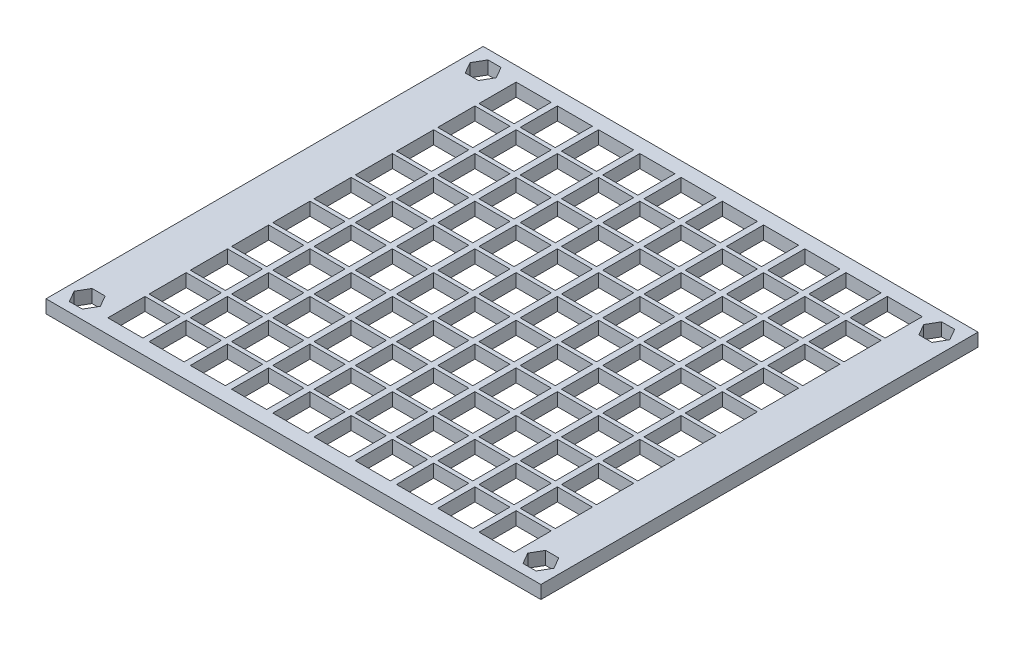
from build123d import *

# Parameters (mm, degrees)
SKETCH1_W           = 120
SKETCH1_H           = 106
SKETCH1_W_2         = 8.5
SKETCH1_H_2         = 9
BOSS_EXTRUDE1_DEPTH = 3.175


with BuildPart() as part:
    # Sketch1 → Boss-Extrude1 (new body)
    with BuildSketch(Plane(origin=(0, 0, 0), x_dir=(1, 0, 0), z_dir=(0, 1, 0))):
        with Locations((60, 53)):
            Rectangle(SKETCH1_W, SKETCH1_H)
        Polygon((6.58771324, 98.25), (8.175426481, 101), (6.58771324, 103.75), (3.41228676, 103.75), (1.824573519, 101), (3.41228676, 98.25), align=None, mode=Mode.SUBTRACT)
        with Locations((25.75, 8)):
            Rectangle(SKETCH1_W_2, SKETCH1_H_2, mode=Mode.SUBTRACT)
        with Locations((15.75, 8)):
            Rectangle(SKETCH1_W_2, SKETCH1_H_2, mode=Mode.SUBTRACT)
        with Locations((35.75, 8)):
            Rectangle(SKETCH1_W_2, SKETCH1_H_2, mode=Mode.SUBTRACT)
        with Locations((45.75, 8)):
            Rectangle(SKETCH1_W_2, SKETCH1_H_2, mode=Mode.SUBTRACT)
        with Locations((55.75, 8)):
            Rectangle(SKETCH1_W_2, SKETCH1_H_2, mode=Mode.SUBTRACT)
        with Locations((65.75, 8)):
            Rectangle(SKETCH1_W_2, SKETCH1_H_2, mode=Mode.SUBTRACT)
        with Locations((75.75, 8)):
            Rectangle(SKETCH1_W_2, SKETCH1_H_2, mode=Mode.SUBTRACT)
        with Locations((85.75, 8)):
            Rectangle(SKETCH1_W_2, SKETCH1_H_2, mode=Mode.SUBTRACT)
        with Locations((95.75, 8)):
            Rectangle(SKETCH1_W_2, SKETCH1_H_2, mode=Mode.SUBTRACT)
        with Locations((105.75, 8)):
            Rectangle(SKETCH1_W_2, SKETCH1_H_2, mode=Mode.SUBTRACT)
        with Locations((25.75, 18)):
            Rectangle(SKETCH1_W_2, SKETCH1_H_2, mode=Mode.SUBTRACT)
        with Locations((35.75, 18)):
            Rectangle(SKETCH1_W_2, SKETCH1_H_2, mode=Mode.SUBTRACT)
        with Locations((45.75, 18)):
            Rectangle(SKETCH1_W_2, SKETCH1_H_2, mode=Mode.SUBTRACT)
        with Locations((55.75, 18)):
            Rectangle(SKETCH1_W_2, SKETCH1_H_2, mode=Mode.SUBTRACT)
        with Locations((65.75, 18)):
            Rectangle(SKETCH1_W_2, SKETCH1_H_2, mode=Mode.SUBTRACT)
        with Locations((75.75, 18)):
            Rectangle(SKETCH1_W_2, SKETCH1_H_2, mode=Mode.SUBTRACT)
        with Locations((85.75, 18)):
            Rectangle(SKETCH1_W_2, SKETCH1_H_2, mode=Mode.SUBTRACT)
        with Locations((95.75, 18)):
            Rectangle(SKETCH1_W_2, SKETCH1_H_2, mode=Mode.SUBTRACT)
        with Locations((105.75, 18)):
            Rectangle(SKETCH1_W_2, SKETCH1_H_2, mode=Mode.SUBTRACT)
        with Locations((25.75, 28)):
            Rectangle(SKETCH1_W_2, SKETCH1_H_2, mode=Mode.SUBTRACT)
        with Locations((35.75, 28)):
            Rectangle(SKETCH1_W_2, SKETCH1_H_2, mode=Mode.SUBTRACT)
        with Locations((45.75, 28)):
            Rectangle(SKETCH1_W_2, SKETCH1_H_2, mode=Mode.SUBTRACT)
        with Locations((55.75, 28)):
            Rectangle(SKETCH1_W_2, SKETCH1_H_2, mode=Mode.SUBTRACT)
        with Locations((65.75, 28)):
            Rectangle(SKETCH1_W_2, SKETCH1_H_2, mode=Mode.SUBTRACT)
        with Locations((75.75, 28)):
            Rectangle(SKETCH1_W_2, SKETCH1_H_2, mode=Mode.SUBTRACT)
        with Locations((85.75, 28)):
            Rectangle(SKETCH1_W_2, SKETCH1_H_2, mode=Mode.SUBTRACT)
        with Locations((95.75, 28)):
            Rectangle(SKETCH1_W_2, SKETCH1_H_2, mode=Mode.SUBTRACT)
        with Locations((105.75, 28)):
            Rectangle(SKETCH1_W_2, SKETCH1_H_2, mode=Mode.SUBTRACT)
        with Locations((25.75, 38)):
            Rectangle(SKETCH1_W_2, SKETCH1_H_2, mode=Mode.SUBTRACT)
        with Locations((35.75, 38)):
            Rectangle(SKETCH1_W_2, SKETCH1_H_2, mode=Mode.SUBTRACT)
        with Locations((45.75, 38)):
            Rectangle(SKETCH1_W_2, SKETCH1_H_2, mode=Mode.SUBTRACT)
        with Locations((55.75, 38)):
            Rectangle(SKETCH1_W_2, SKETCH1_H_2, mode=Mode.SUBTRACT)
        with Locations((65.75, 38)):
            Rectangle(SKETCH1_W_2, SKETCH1_H_2, mode=Mode.SUBTRACT)
        with Locations((75.75, 38)):
            Rectangle(SKETCH1_W_2, SKETCH1_H_2, mode=Mode.SUBTRACT)
        with Locations((85.75, 38)):
            Rectangle(SKETCH1_W_2, SKETCH1_H_2, mode=Mode.SUBTRACT)
        with Locations((95.75, 38)):
            Rectangle(SKETCH1_W_2, SKETCH1_H_2, mode=Mode.SUBTRACT)
        with Locations((105.75, 38)):
            Rectangle(SKETCH1_W_2, SKETCH1_H_2, mode=Mode.SUBTRACT)
        with Locations((25.75, 48)):
            Rectangle(SKETCH1_W_2, SKETCH1_H_2, mode=Mode.SUBTRACT)
        with Locations((35.75, 48)):
            Rectangle(SKETCH1_W_2, SKETCH1_H_2, mode=Mode.SUBTRACT)
        with Locations((45.75, 48)):
            Rectangle(SKETCH1_W_2, SKETCH1_H_2, mode=Mode.SUBTRACT)
        with Locations((55.75, 48)):
            Rectangle(SKETCH1_W_2, SKETCH1_H_2, mode=Mode.SUBTRACT)
        with Locations((65.75, 48)):
            Rectangle(SKETCH1_W_2, SKETCH1_H_2, mode=Mode.SUBTRACT)
        with Locations((75.75, 48)):
            Rectangle(SKETCH1_W_2, SKETCH1_H_2, mode=Mode.SUBTRACT)
        with Locations((85.75, 48)):
            Rectangle(SKETCH1_W_2, SKETCH1_H_2, mode=Mode.SUBTRACT)
        with Locations((95.75, 48)):
            Rectangle(SKETCH1_W_2, SKETCH1_H_2, mode=Mode.SUBTRACT)
        with Locations((105.75, 48)):
            Rectangle(SKETCH1_W_2, SKETCH1_H_2, mode=Mode.SUBTRACT)
        with Locations((25.75, 58)):
            Rectangle(SKETCH1_W_2, SKETCH1_H_2, mode=Mode.SUBTRACT)
        with Locations((35.75, 58)):
            Rectangle(SKETCH1_W_2, SKETCH1_H_2, mode=Mode.SUBTRACT)
        with Locations((45.75, 58)):
            Rectangle(SKETCH1_W_2, SKETCH1_H_2, mode=Mode.SUBTRACT)
        with Locations((55.75, 58)):
            Rectangle(SKETCH1_W_2, SKETCH1_H_2, mode=Mode.SUBTRACT)
        with Locations((65.75, 58)):
            Rectangle(SKETCH1_W_2, SKETCH1_H_2, mode=Mode.SUBTRACT)
        with Locations((75.75, 58)):
            Rectangle(SKETCH1_W_2, SKETCH1_H_2, mode=Mode.SUBTRACT)
        with Locations((85.75, 58)):
            Rectangle(SKETCH1_W_2, SKETCH1_H_2, mode=Mode.SUBTRACT)
        with Locations((95.75, 58)):
            Rectangle(SKETCH1_W_2, SKETCH1_H_2, mode=Mode.SUBTRACT)
        with Locations((105.75, 58)):
            Rectangle(SKETCH1_W_2, SKETCH1_H_2, mode=Mode.SUBTRACT)
        with Locations((25.75, 68)):
            Rectangle(SKETCH1_W_2, SKETCH1_H_2, mode=Mode.SUBTRACT)
        with Locations((35.75, 68)):
            Rectangle(SKETCH1_W_2, SKETCH1_H_2, mode=Mode.SUBTRACT)
        with Locations((45.75, 68)):
            Rectangle(SKETCH1_W_2, SKETCH1_H_2, mode=Mode.SUBTRACT)
        with Locations((55.75, 68)):
            Rectangle(SKETCH1_W_2, SKETCH1_H_2, mode=Mode.SUBTRACT)
        with Locations((65.75, 68)):
            Rectangle(SKETCH1_W_2, SKETCH1_H_2, mode=Mode.SUBTRACT)
        with Locations((75.75, 68)):
            Rectangle(SKETCH1_W_2, SKETCH1_H_2, mode=Mode.SUBTRACT)
        with Locations((85.75, 68)):
            Rectangle(SKETCH1_W_2, SKETCH1_H_2, mode=Mode.SUBTRACT)
        with Locations((95.75, 68)):
            Rectangle(SKETCH1_W_2, SKETCH1_H_2, mode=Mode.SUBTRACT)
        with Locations((105.75, 68)):
            Rectangle(SKETCH1_W_2, SKETCH1_H_2, mode=Mode.SUBTRACT)
        with Locations((25.75, 78)):
            Rectangle(SKETCH1_W_2, SKETCH1_H_2, mode=Mode.SUBTRACT)
        with Locations((35.75, 78)):
            Rectangle(SKETCH1_W_2, SKETCH1_H_2, mode=Mode.SUBTRACT)
        with Locations((45.75, 78)):
            Rectangle(SKETCH1_W_2, SKETCH1_H_2, mode=Mode.SUBTRACT)
        with Locations((55.75, 78)):
            Rectangle(SKETCH1_W_2, SKETCH1_H_2, mode=Mode.SUBTRACT)
        with Locations((65.75, 78)):
            Rectangle(SKETCH1_W_2, SKETCH1_H_2, mode=Mode.SUBTRACT)
        with Locations((75.75, 78)):
            Rectangle(SKETCH1_W_2, SKETCH1_H_2, mode=Mode.SUBTRACT)
        with Locations((85.75, 78)):
            Rectangle(SKETCH1_W_2, SKETCH1_H_2, mode=Mode.SUBTRACT)
        with Locations((95.75, 78)):
            Rectangle(SKETCH1_W_2, SKETCH1_H_2, mode=Mode.SUBTRACT)
        with Locations((105.75, 78)):
            Rectangle(SKETCH1_W_2, SKETCH1_H_2, mode=Mode.SUBTRACT)
        with Locations((25.75, 88)):
            Rectangle(SKETCH1_W_2, SKETCH1_H_2, mode=Mode.SUBTRACT)
        with Locations((35.75, 88)):
            Rectangle(SKETCH1_W_2, SKETCH1_H_2, mode=Mode.SUBTRACT)
        with Locations((45.75, 88)):
            Rectangle(SKETCH1_W_2, SKETCH1_H_2, mode=Mode.SUBTRACT)
        with Locations((55.75, 88)):
            Rectangle(SKETCH1_W_2, SKETCH1_H_2, mode=Mode.SUBTRACT)
        with Locations((65.75, 88)):
            Rectangle(SKETCH1_W_2, SKETCH1_H_2, mode=Mode.SUBTRACT)
        with Locations((75.75, 88)):
            Rectangle(SKETCH1_W_2, SKETCH1_H_2, mode=Mode.SUBTRACT)
        with Locations((85.75, 88)):
            Rectangle(SKETCH1_W_2, SKETCH1_H_2, mode=Mode.SUBTRACT)
        with Locations((95.75, 88)):
            Rectangle(SKETCH1_W_2, SKETCH1_H_2, mode=Mode.SUBTRACT)
        with Locations((105.75, 88)):
            Rectangle(SKETCH1_W_2, SKETCH1_H_2, mode=Mode.SUBTRACT)
        with Locations((25.75, 98)):
            Rectangle(SKETCH1_W_2, SKETCH1_H_2, mode=Mode.SUBTRACT)
        with Locations((35.75, 98)):
            Rectangle(SKETCH1_W_2, SKETCH1_H_2, mode=Mode.SUBTRACT)
        with Locations((45.75, 98)):
            Rectangle(SKETCH1_W_2, SKETCH1_H_2, mode=Mode.SUBTRACT)
        with Locations((55.75, 98)):
            Rectangle(SKETCH1_W_2, SKETCH1_H_2, mode=Mode.SUBTRACT)
        with Locations((65.75, 98)):
            Rectangle(SKETCH1_W_2, SKETCH1_H_2, mode=Mode.SUBTRACT)
        with Locations((75.75, 98)):
            Rectangle(SKETCH1_W_2, SKETCH1_H_2, mode=Mode.SUBTRACT)
        with Locations((85.75, 98)):
            Rectangle(SKETCH1_W_2, SKETCH1_H_2, mode=Mode.SUBTRACT)
        with Locations((95.75, 98)):
            Rectangle(SKETCH1_W_2, SKETCH1_H_2, mode=Mode.SUBTRACT)
        with Locations((105.75, 98)):
            Rectangle(SKETCH1_W_2, SKETCH1_H_2, mode=Mode.SUBTRACT)
        with Locations((15.75, 18)):
            Rectangle(SKETCH1_W_2, SKETCH1_H_2, mode=Mode.SUBTRACT)
        with Locations((15.75, 28)):
            Rectangle(SKETCH1_W_2, SKETCH1_H_2, mode=Mode.SUBTRACT)
        with Locations((15.75, 38)):
            Rectangle(SKETCH1_W_2, SKETCH1_H_2, mode=Mode.SUBTRACT)
        with Locations((15.75, 48)):
            Rectangle(SKETCH1_W_2, SKETCH1_H_2, mode=Mode.SUBTRACT)
        with Locations((15.75, 58)):
            Rectangle(SKETCH1_W_2, SKETCH1_H_2, mode=Mode.SUBTRACT)
        with Locations((15.75, 68)):
            Rectangle(SKETCH1_W_2, SKETCH1_H_2, mode=Mode.SUBTRACT)
        with Locations((15.75, 78)):
            Rectangle(SKETCH1_W_2, SKETCH1_H_2, mode=Mode.SUBTRACT)
        with Locations((15.75, 88)):
            Rectangle(SKETCH1_W_2, SKETCH1_H_2, mode=Mode.SUBTRACT)
        with Locations((15.75, 98)):
            Rectangle(SKETCH1_W_2, SKETCH1_H_2, mode=Mode.SUBTRACT)
        Polygon((113.41228676, 103.75), (111.824573519, 101), (113.41228676, 98.25), (116.58771324, 98.25), (118.175426481, 101), (116.58771324, 103.75), align=None, mode=Mode.SUBTRACT)
        Polygon((113.41228676, 7.75), (111.824573519, 5), (113.41228676, 2.25), (116.58771324, 2.25), (118.175426481, 5), (116.58771324, 7.75), align=None, mode=Mode.SUBTRACT)
        Polygon((1.824573519, 5), (3.41228676, 2.25), (6.58771324, 2.25), (8.175426481, 5), (6.58771324, 7.75), (3.41228676, 7.75), align=None, mode=Mode.SUBTRACT)
    extrude(amount=BOSS_EXTRUDE1_DEPTH)


solid = part.part
